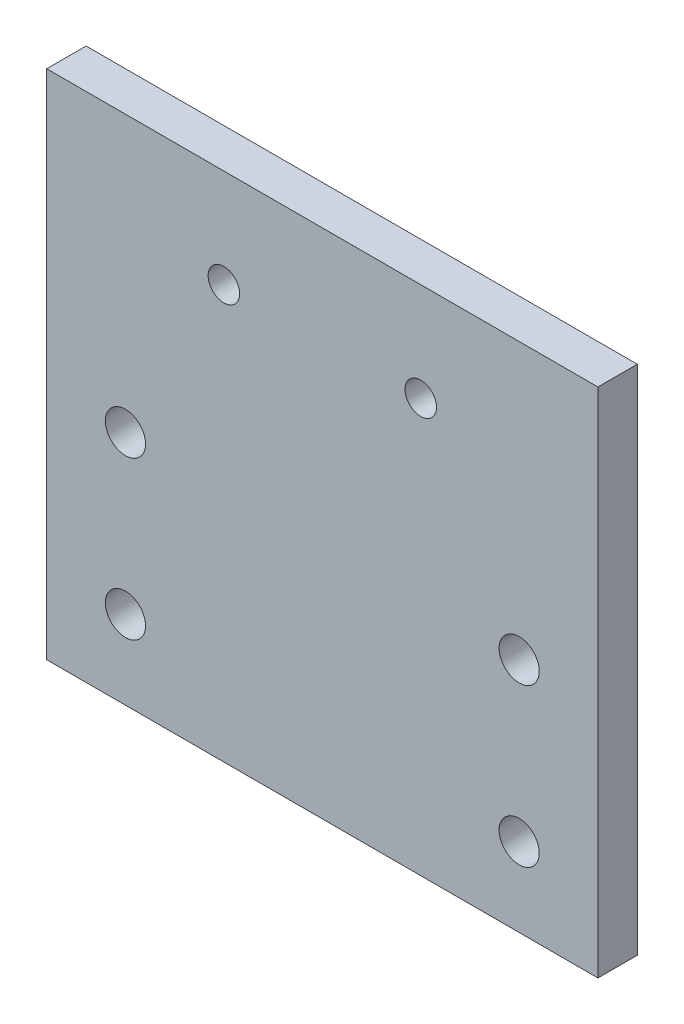
from build123d import *

# Parameters (mm, degrees)
SKETCH1_R           = 2.55
SKETCH1_R_2         = 2
BOSS_EXTRUDE1_DEPTH = 5


with BuildPart() as part:
    # Sketch1 → Boss-Extrude1 (new body)
    with BuildSketch(Plane.XY):
        Polygon((-35, -12.5), (-35, -52.5), (35, -52.5), (35, -12.5), (35, 12.5), (-35, 12.5), align=None)
        with Locations((-25, -22.5)):
            Circle(SKETCH1_R, mode=Mode.SUBTRACT)
        with Locations((-25, -42.5)):
            Circle(SKETCH1_R, mode=Mode.SUBTRACT)
        with Locations((25, -42.5)):
            Circle(SKETCH1_R, mode=Mode.SUBTRACT)
        with Locations((25, -22.5)):
            Circle(SKETCH1_R, mode=Mode.SUBTRACT)
        with Locations((-12.5, 0)):
            Circle(SKETCH1_R_2, mode=Mode.SUBTRACT)
        with Locations((12.5, 0)):
            Circle(SKETCH1_R_2, mode=Mode.SUBTRACT)
    extrude(amount=BOSS_EXTRUDE1_DEPTH)


solid = part.part
